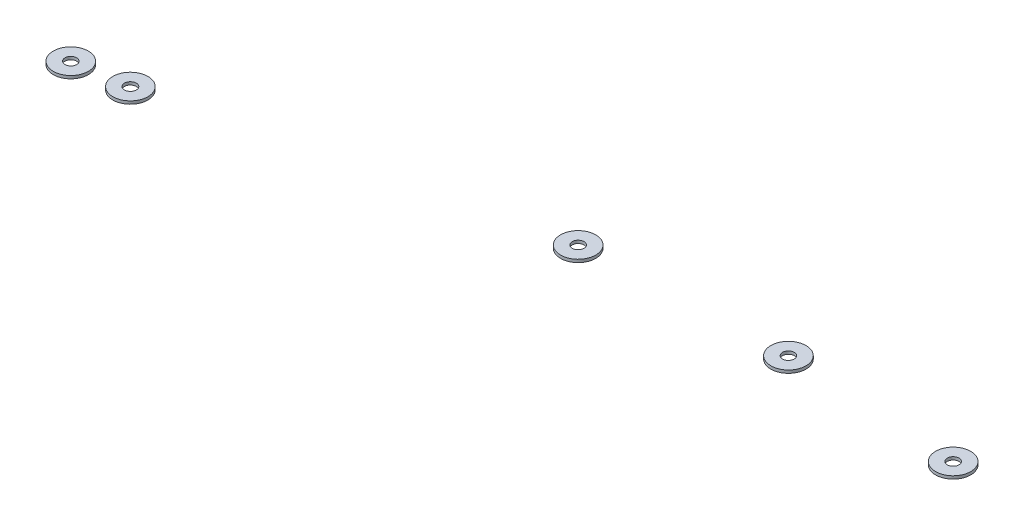
from build123d import *

# Parameters (mm, degrees)
SZKIC1_R                      = 6
SZKIC1_R_2                    = 2
DODANIE_WYCI_GNI_CIE1_DEPTH   = 1
DODANIE_WYCI_GNI_CIE1_2_DEPTH = 1
DODANIE_WYCI_GNI_CIE1_3_DEPTH = 1
SZKIC1_R_3                    = 2.034219479
DODANIE_WYCI_GNI_CIE1_4_DEPTH = 1
DODANIE_WYCI_GNI_CIE1_5_DEPTH = 1


with BuildPart() as part:
    # Szkic1 → Dodanie-wyciągnięcie1 (new body)
    with BuildSketch(Plane(origin=(0, 705.3, 0), x_dir=(1, 0, 0), z_dir=(0, 1, 0))):
        with Locations((-94.909521544, -263.802212936)):
            Circle(SZKIC1_R)
        with Locations((-94.909521544, -263.802212936)):
            Circle(SZKIC1_R_2, mode=Mode.SUBTRACT)
    extrude(amount=DODANIE_WYCI_GNI_CIE1_DEPTH)


with BuildPart() as body_2:
    # Szkic1 → Dodanie-wyci_gni_cie1 2 (new body)
    with BuildSketch(Plane(origin=(0, 705.3, 0), x_dir=(1, 0, 0), z_dir=(0, 1, 0))):
        with Locations((-154.344703344, -260.643821632)):
            Circle(SZKIC1_R)
        with Locations((-154.344703344, -260.643821632)):
            Circle(SZKIC1_R_2, mode=Mode.SUBTRACT)
    extrude(amount=DODANIE_WYCI_GNI_CIE1_2_DEPTH)


with BuildPart() as body_3:
    # Szkic1 → Dodanie-wyci_gni_cie1 3 (new body)
    with BuildSketch(Plane(origin=(0, 705.3, 0), x_dir=(1, 0, 0), z_dir=(0, 1, 0))):
        with Locations((-223.024834581, -263.802212936)):
            Circle(SZKIC1_R)
        with Locations((-223.024834581, -263.802212936)):
            Circle(SZKIC1_R_2, mode=Mode.SUBTRACT)
    extrude(amount=DODANIE_WYCI_GNI_CIE1_3_DEPTH)


with BuildPart() as body_4:
    # Szkic1 → Dodanie-wyci_gni_cie1 4 (new body)
    with BuildSketch(Plane(origin=(0, 705.3, 0), x_dir=(1, 0, 0), z_dir=(0, 1, 0))):
        with Locations((-346.372819064, -293.429327819)):
            Circle(SZKIC1_R)
        with Locations((-346.372819064, -293.429327819)):
            Circle(SZKIC1_R_3, mode=Mode.SUBTRACT)
    extrude(amount=DODANIE_WYCI_GNI_CIE1_4_DEPTH)


with BuildPart() as body_5:
    # Szkic1 → Dodanie-wyci_gni_cie1 5 (new body)
    with BuildSketch(Plane(origin=(0, 705.3, 0), x_dir=(1, 0, 0), z_dir=(0, 1, 0))):
        with Locations((-364.051137421, -296.101801859)):
            Circle(SZKIC1_R)
        with Locations((-364.051137421, -296.101801859)):
            Circle(SZKIC1_R_2, mode=Mode.SUBTRACT)
    extrude(amount=DODANIE_WYCI_GNI_CIE1_5_DEPTH)


solid = Compound([part.part, body_2.part, body_3.part, body_4.part, body_5.part])
